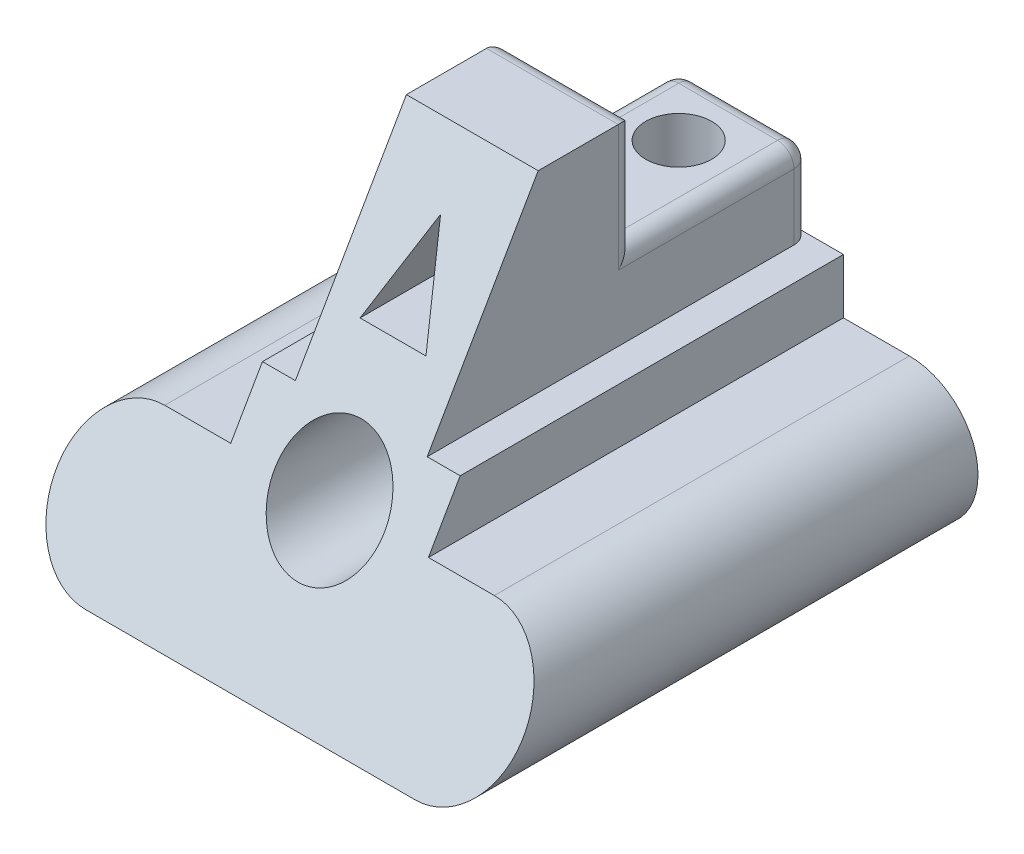
from build123d import *

# Parameters (mm, degrees)
SKETCH1_R               = 10
BOSS_EXTRUDE1_DEPTH     = 90
CUT_EXTRUDE2_DEPTH      = 25.5
CUT_EXTRUDE2_DEPTH_BACK = 61.5
SKETCH4_W               = 32
SKETCH4_H               = 20
CUT_EXTRUDE3_DEPTH      = 55.5
SKETCH5_W               = 24
SKETCH5_H               = 32
BOSS_EXTRUDE2_DEPTH     = 5
F_1_5MM_DOWEL_HOLE1_D   = 12
FILLET1_R               = 3


with BuildPart() as part:
    # Sketch1 → Boss-Extrude1 (new body)
    with BuildSketch(Plane.XY):
        with BuildLine():
            Line((0, 12.5), (12, 12.5))
            Line((12, 12.5), (12, 22.5))
            Line((12, 22.5), (18, 22.5))
            Line((18, 22.5), (18, 57.5))
            Line((18, 57.5), (42, 57.5))
            Line((42, 57.5), (42, 22.5))
            Line((42, 22.5), (48, 22.5))
            Line((48, 22.5), (48, 12.5))
            Line((48, 12.5), (60, 12.5))
            ThreePointArc((60, 12.5), (72.5, 0), (60, -12.5))
            Line((60, -12.5), (0, -12.5))
            ThreePointArc((0, -12.5), (-12.5, 0), (0, 12.5))
        make_face()
        with Locations((30, 12.5)):
            Circle(SKETCH1_R, mode=Mode.SUBTRACT)
        Polygon((24, 32.5), (36, 32.5), (30, 47.5), align=None, mode=Mode.SUBTRACT)
    extrude(amount=-BOSS_EXTRUDE1_DEPTH)

    # Sketch3 → Cut-Extrude2 (cut, two sides)
    with BuildSketch(Plane(origin=(48, 0, 0), x_dir=(0, 0, -1), z_dir=(1, 0, 0))) as cut_extrude2_sk:
        Polygon((-119.01754251, -218.644430619), (0, -12.5), (40.414518843, 57.5), (159.432061353, 263.644430619), (-252.856799885, 501.679515639), (-531.306403748, 19.390654401), align=None)
    extrude(amount=CUT_EXTRUDE2_DEPTH, mode=Mode.SUBTRACT)
    extrude(cut_extrude2_sk.sketch, amount=-CUT_EXTRUDE2_DEPTH_BACK, mode=Mode.SUBTRACT)

    # Sketch4 → Cut-Extrude3 (cut, through all)
    with BuildSketch(Plane.ZY.offset(-18)):
        with Locations((-74, 47.5)):
            Rectangle(SKETCH4_W, SKETCH4_H)
    extrude(amount=-CUT_EXTRUDE3_DEPTH, mode=Mode.SUBTRACT)

    # Sketch5 → Boss-Extrude2 (add)
    with BuildSketch(Plane(origin=(0, 37.5, 0), x_dir=(1, 0, 0), z_dir=(0, 1, 0))):
        with Locations((30, 74)):
            Rectangle(SKETCH5_W, SKETCH5_H)
    extrude(amount=-BOSS_EXTRUDE2_DEPTH)

    # Ø1.5mm Dowel Hole1 (through all)
    with Locations(Plane(origin=(0, 37.5, 0), x_dir=(1, 0, 0), z_dir=(0, 1, 0))):
        with Locations((30, 78)):
            Hole(F_1_5MM_DOWEL_HOLE1_D / 2)

    # Fillet1
    fillet1_edges = [part.edges().sort_by_distance(p)[0] for p in [
        (42, 30, -90),
        (18, 30, -90),
        (30, 37.5, -90),
        (42, 47.5, -58),
        (30, 57.5, -58),
        (42, 37.5, -74),
        (18, 37.5, -74),
        (18, 47.5, -58),
    ]]
    fillet(fillet1_edges, radius=FILLET1_R)


solid = part.part
